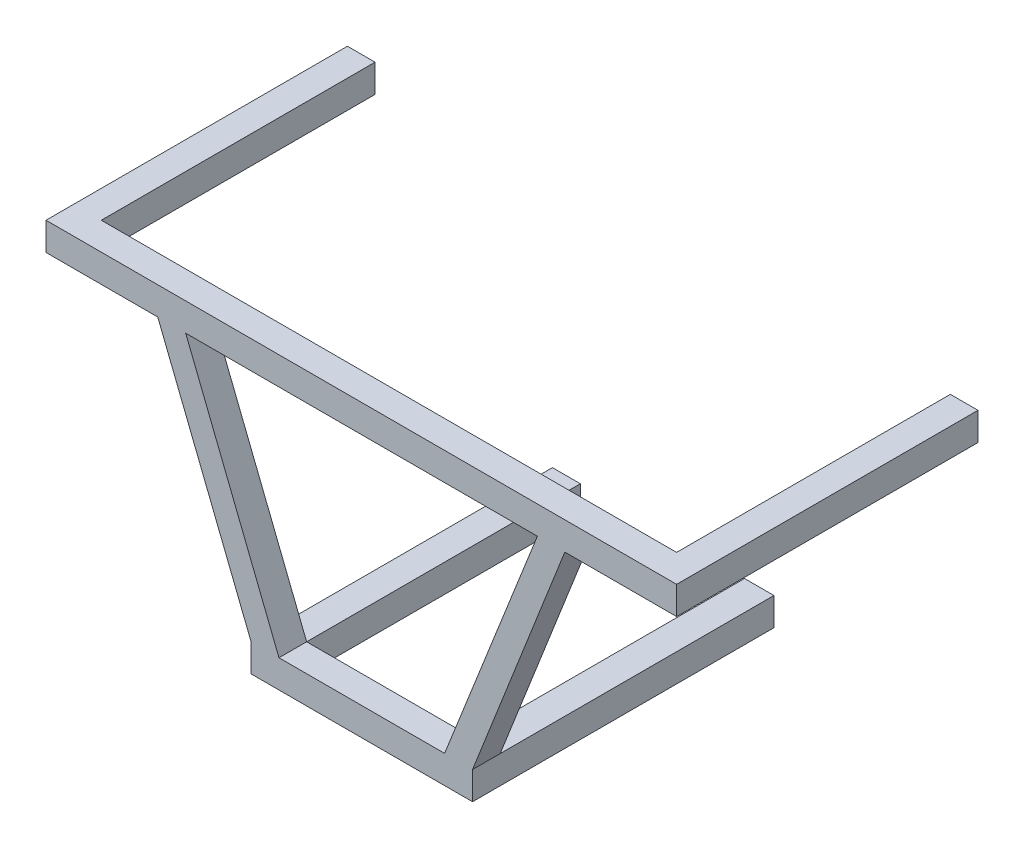
from build123d import *

# Parameters (mm, degrees)
EXTRUDE1_DEPTH      = 10
EXTRUDE2_DEPTH      = 10
EXTRUDE3_DEPTH      = 10
SKETCH2_W           = 9.998469457
SKETCH2_H           = 10.103213958
SKETCH2_W_2         = 10.103213958
SKETCH2_W_3         = 10.643545952
SKETCH2_W_4         = 9.998494457
EXTRUDE4_DEPTH      = 10
EXTRUDE4_DEPTH_BACK = 99


with BuildPart() as part:
    # Sketch1 → Extrude1 (new body)
    with BuildSketch(Plane.XY):
        Polygon((63.686330841, 43.028866588), (73.609130264, 43.028866588), (114.021986095, 43.028866588), (114.021986095, 53.132080546), (-114.021986095, 53.132080546), (-114.021986095, 43.028866588), (-73.609130264, 43.028866588), (-63.505916306, 43.028866588), align=None)
    extrude(amount=EXTRUDE1_DEPTH)



with BuildPart() as body_2:
    # Sketch1_3 → Extrude2 (new body)
    with BuildSketch(Plane.XY):
        Polygon((40.232441296, -51.869178801), (40.232441296, -41.765964843), (30.129227338, -41.765964843), (-29.768398268, -41.765964843), (-39.871612226, -41.765964843), (-39.871612226, -51.869178801), align=None)
    extrude(amount=EXTRUDE2_DEPTH)


with BuildPart() as part_1:
    add(part.part)

    add(body_2.part)  # Extrude3 merges body 2
    # Sketch1_4 → Extrude3 (add)
    with BuildSketch(Plane.XY):
        Polygon((40.232441296, -41.765964843), (73.609130264, 43.028866588), (63.686330841, 43.028866588), (30.129227338, -41.765964843), align=None)
        Polygon((-29.768398268, -41.765964843), (-63.505916306, 43.028866588), (-73.609130264, 43.028866588), (-39.871612226, -41.765964843), align=None)
    extrude(amount=EXTRUDE3_DEPTH)

    # Sketch2 → Extrude4 (add, two sides)
    with BuildSketch(Plane.XY) as extrude4_sk:
        with Locations((-109.022751367, 48.080473567)):
            Rectangle(SKETCH2_W, SKETCH2_H)
        with Locations((-34.820005247, -46.817571822)):
            Rectangle(SKETCH2_W_2, SKETCH2_H)
        with Locations((34.91066832, -46.817571822)):
            Rectangle(SKETCH2_W_3, SKETCH2_H)
        with Locations((109.022738867, 48.080473567)):
            Rectangle(SKETCH2_W_4, SKETCH2_H)
    extrude(amount=EXTRUDE4_DEPTH)
    extrude(extrude4_sk.sketch, amount=-EXTRUDE4_DEPTH_BACK)


solid = part_1.part
